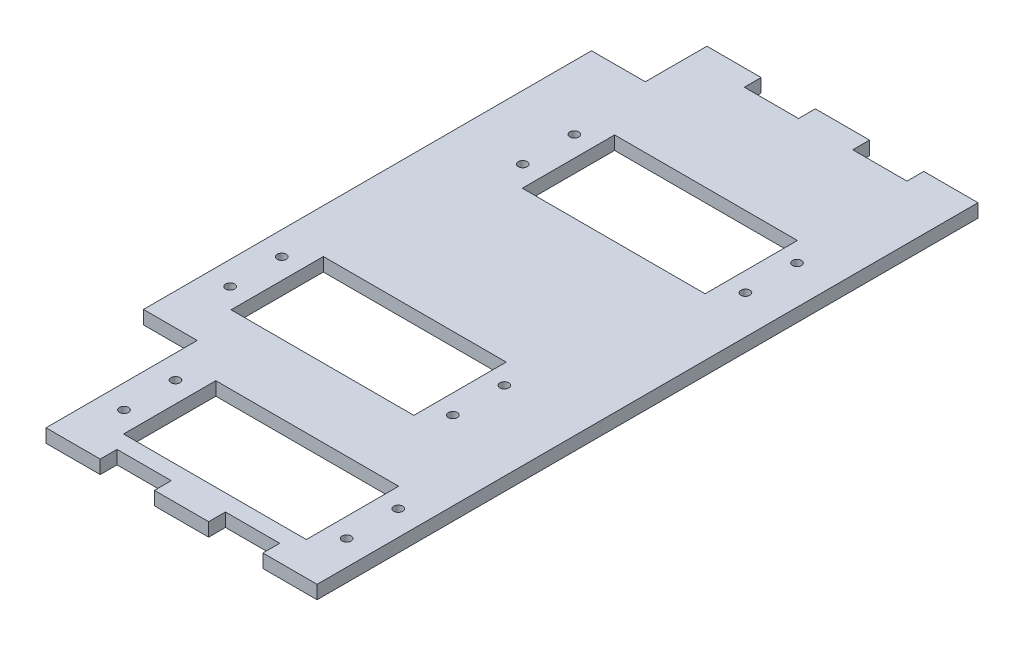
from build123d import *

# Parameters (mm, degrees)
SKETCH1_W           = 40.8
SKETCH1_H           = 20.6
BOSS_EXTRUDE4_DEPTH = 3
SKETCH2_R           = 1
CUT_EXTRUDE1_DEPTH  = 4


with BuildPart() as part:
    # Sketch1 → Boss-Extrude4 (new body)
    with BuildSketch(Plane(origin=(0, 0, 0), x_dir=(1, 0, 0), z_dir=(0, 1, 0))):
        Polygon((30.25, -70), (30.25, 70), (30.25, 73.75), (18.15, 73.75), (18.15, 70), (6.05, 70), (6.05, 73.75), (-6.05, 73.75), (-6.05, 70), (-18.15, 70), (-18.15, 73.75), (-30.25, 73.75), (-30.25, 70), (-30.25, 60), (-42.25, 60), (-42.25, -40), (-30.25, -40), (-30.25, -70), (-30.25, -73.75), (-18.15, -73.75), (-18.15, -70), (-6.05, -70), (-6.05, -73.75), (6.05, -73.75), (6.05, -70), (18.15, -70), (18.15, -73.75), (30.25, -73.75), align=None)
        with Locations((0, -56)):
            Rectangle(SKETCH1_W, SKETCH1_H, mode=Mode.SUBTRACT)
        with Locations((-12, -20)):
            Rectangle(SKETCH1_W, SKETCH1_H, mode=Mode.SUBTRACT)
        with Locations((-3, 36)):
            Rectangle(SKETCH1_W, SKETCH1_H, mode=Mode.SUBTRACT)
    extrude(amount=BOSS_EXTRUDE4_DEPTH)

    # Sketch2 → Cut-Extrude1 (cut, through all)
    with BuildSketch(Plane(origin=(0, 3, 0), x_dir=(1, 0, 0), z_dir=(0, 1, 0))):
        with Locations((-25, -50.1)):
            Circle(SKETCH2_R)
        with Locations((-25, -61.6)):
            Circle(SKETCH2_R)
        with Locations((-37, -25.9)):
            Circle(SKETCH2_R)
        with Locations((-28, 30.4)):
            Circle(SKETCH2_R)
        with Locations((-28, 41.9)):
            Circle(SKETCH2_R)
        with Locations((21.7, 41.9)):
            Circle(SKETCH2_R)
        with Locations((21.7, 30.4)):
            Circle(SKETCH2_R)
        with Locations((12.7, -14.4)):
            Circle(SKETCH2_R)
        with Locations((12.7, -25.9)):
            Circle(SKETCH2_R)
        with Locations((24.7, -50.1)):
            Circle(SKETCH2_R)
        with Locations((24.7, -61.6)):
            Circle(SKETCH2_R)
        with Locations((-37, -14.4)):
            Circle(SKETCH2_R)
    extrude(amount=-CUT_EXTRUDE1_DEPTH, mode=Mode.SUBTRACT)


solid = part.part
